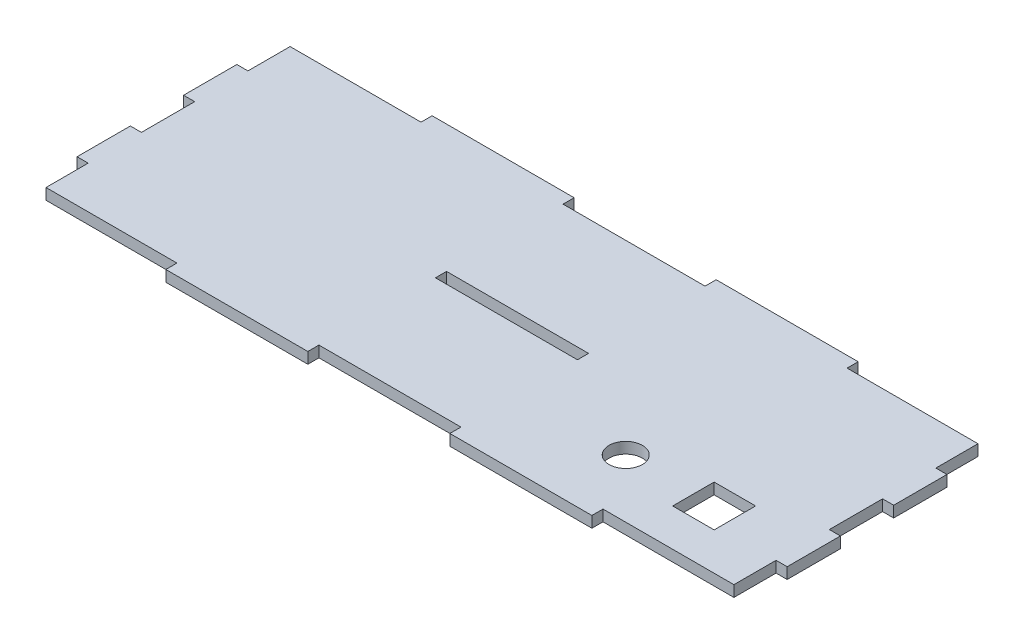
from build123d import *

# Parameters (mm, degrees)
SKETCH1_W           = 203.2
SKETCH1_H           = 76.2
BOSS_EXTRUDE1_DEPTH = 3.175
SKETCH2_W           = 40.64
SKETCH2_H           = 3.175
CUT_EXTRUDE1_DEPTH  = 3.175
LPATTERN1_COUNT     = 3
LPATTERN1_PITCH     = 81.28
SKETCH3_W           = 3.175
SKETCH3_H           = 15.24
CUT_EXTRUDE2_DEPTH  = 3.175
LPATTERN2_COUNT     = 3
LPATTERN2_PITCH     = 30.48
SKETCH4_R           = 4.7625
SKETCH4_W           = 11.8618
SKETCH4_H           = 11.8618
CUT_EXTRUDE5_DEPTH  = 3.175
SKETCH5_W           = 40.64
SKETCH5_H           = 3.175
CUT_EXTRUDE6_DEPTH  = 3.175


with BuildPart() as part:
    # Sketch1 → Boss-Extrude1 (new body)
    with BuildSketch(Plane(origin=(0, 0, 0), x_dir=(1, 0, 0), z_dir=(0, 1, 0))):
        Rectangle(SKETCH1_W, SKETCH1_H)
    extrude(amount=BOSS_EXTRUDE1_DEPTH)

    # Sketch2 → Cut-Extrude1 (cut)
    with BuildSketch(Plane(origin=(0, 3.175, 0), x_dir=(1, 0, 0), z_dir=(0, 1, 0))):
        with Locations((-81.28, 36.5125)):
            Rectangle(SKETCH2_W, SKETCH2_H)
        with Locations((-81.28, -36.5125)):
            Rectangle(SKETCH2_W, SKETCH2_H)
    cut_extrude1 = extrude(amount=-CUT_EXTRUDE1_DEPTH, mode=Mode.SUBTRACT)

    # LPattern1: Cut-Extrude1 ×3
    with Locations(*[(i * LPATTERN1_PITCH, 0, 0) for i in range(1, LPATTERN1_COUNT)]):
        add(cut_extrude1, mode=Mode.SUBTRACT)

    # Sketch3 → Cut-Extrude2 (cut)
    with BuildSketch(Plane(origin=(0, 3.175, 0), x_dir=(1, 0, 0), z_dir=(0, 1, 0))):
        with Locations((100.0125, 30.48)):
            Rectangle(SKETCH3_W, SKETCH3_H)
        with Locations((-100.0125, 30.48)):
            Rectangle(SKETCH3_W, SKETCH3_H)
    cut_extrude2 = extrude(amount=-CUT_EXTRUDE2_DEPTH, mode=Mode.SUBTRACT)

    # LPattern2: Cut-Extrude2 ×3
    with Locations(*[(0, 0, i * LPATTERN2_PITCH) for i in range(1, LPATTERN2_COUNT)]):
        add(cut_extrude2, mode=Mode.SUBTRACT)

    # Sketch4 → Cut-Extrude5 (cut)
    with BuildSketch(Plane(origin=(0, 3.175, 0), x_dir=(1, 0, 0), z_dir=(0, 1, 0))):
        with Locations((50.8, -18.25625)):
            Circle(SKETCH4_R)
        with Locations((76.099679649, -18.25625)):
            Rectangle(SKETCH4_W, SKETCH4_H)
    extrude(amount=-CUT_EXTRUDE5_DEPTH, mode=Mode.SUBTRACT)

    # Sketch5 → Cut-Extrude6 (cut)
    with BuildSketch(Plane(origin=(0, 3.175, 0), x_dir=(1, 0, 0), z_dir=(0, 1, 0))):
        Rectangle(SKETCH5_W, SKETCH5_H)
    extrude(amount=-CUT_EXTRUDE6_DEPTH, mode=Mode.SUBTRACT)


solid = part.part
